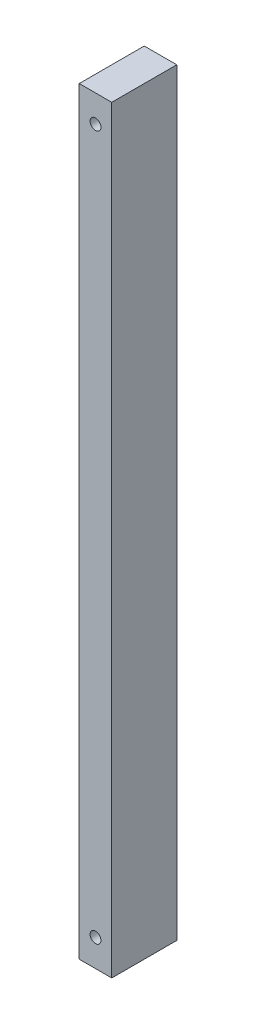
from build123d import *

# Parameters (mm, degrees)
SKETCH1_W           = 38.1
SKETCH1_H           = 444.5
BOSS_EXTRUDE1_DEPTH = 19.05
SKETCH2_R           = 3.175
CUT_EXTRUDE1_DEPTH  = 39.1


with BuildPart() as part:
    # Sketch1 → Boss-Extrude1 (new body)
    with BuildSketch(Plane(origin=(0, 0, 0), x_dir=(0, 0, -1), z_dir=(1, 0, 0))):
        with Locations((19.05, 222.25)):
            Rectangle(SKETCH1_W, SKETCH1_H)
    extrude(amount=BOSS_EXTRUDE1_DEPTH)

    # Sketch2 → Cut-Extrude1 (cut, through all)
    with BuildSketch(Plane.XY):
        with Locations((9.525, 15.875)):
            Circle(SKETCH2_R)
        with Locations((9.525, 428.625)):
            Circle(SKETCH2_R)
    extrude(amount=-CUT_EXTRUDE1_DEPTH, mode=Mode.SUBTRACT)


solid = part.part
